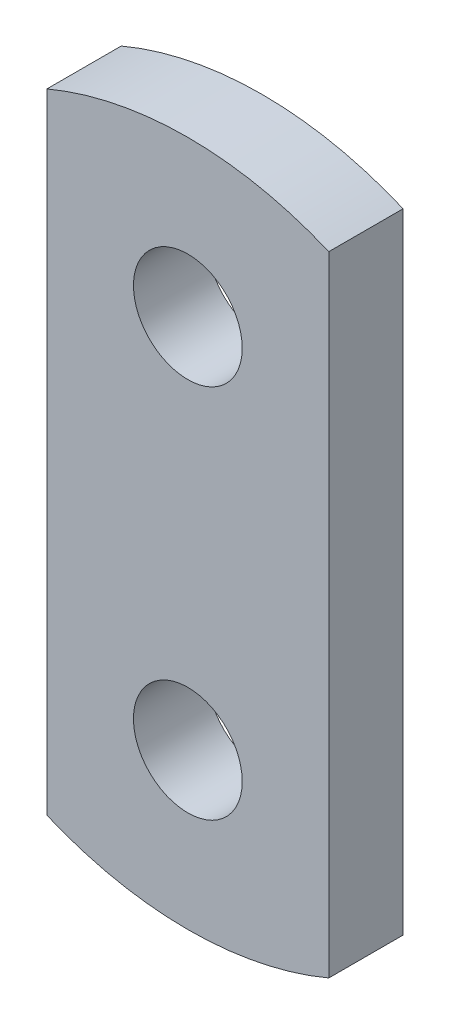
from build123d import *

# Parameters (mm, degrees)
SALIENTE_EXTRUIR2_DEPTH = 8.2


with BuildPart() as part:
    # Croquis1 → Saliente-Extruir2 (new body)
    with BuildSketch(Plane.XY):
        with BuildLine():
            Line((0, 69.4), (0, 34.7))
            Line((0, 34.7), (15.55, 34.7))
            Line((15.55, 34.7), (15.55, 49.4))
            ThreePointArc((15.55, 49.4), (9.55, 55.4), (15.55, 61.4))
            Line((15.55, 61.4), (15.55, 72.55))
            ThreePointArc((15.55, 72.55), (7.617078092, 71.754582753), (0, 69.4))
        make_face()
        with BuildLine():
            Line((15.55, 49.4), (15.55, 34.7))
            Line((15.55, 34.7), (31.1, 34.7))
            Line((31.1, 34.7), (31.1, 69.4))
            ThreePointArc((31.1, 69.4), (23.482921908, 71.754582753), (15.55, 72.55))
            Line((15.55, 72.55), (15.55, 61.4))
            ThreePointArc((15.55, 61.4), (19.792640687, 59.642640687), (21.55, 55.4))
            ThreePointArc((21.55, 55.4), (19.792640687, 51.157359313), (15.55, 49.4))
        make_face()
        with BuildLine():
            Line((0, 34.7), (0, 0))
            ThreePointArc((0, 0), (7.617078092, -2.354582753), (15.55, -3.15))
            Line((15.55, -3.15), (15.55, 8))
            ThreePointArc((15.55, 8), (9.55, 14), (15.55, 20))
            Line((15.55, 20), (15.55, 34.7))
            Line((15.55, 34.7), (0, 34.7))
        make_face()
        with BuildLine():
            Line((15.55, 8), (15.55, -3.15))
            ThreePointArc((15.55, -3.15), (23.482921908, -2.354582753), (31.1, 0))
            Line((31.1, 0), (31.1, 34.7))
            Line((31.1, 34.7), (15.55, 34.7))
            Line((15.55, 34.7), (15.55, 20))
            ThreePointArc((15.55, 20), (19.792640687, 18.242640687), (21.55, 14))
            ThreePointArc((21.55, 14), (19.792640687, 9.757359313), (15.55, 8))
        make_face()
    extrude(amount=SALIENTE_EXTRUIR2_DEPTH)


solid = part.part
